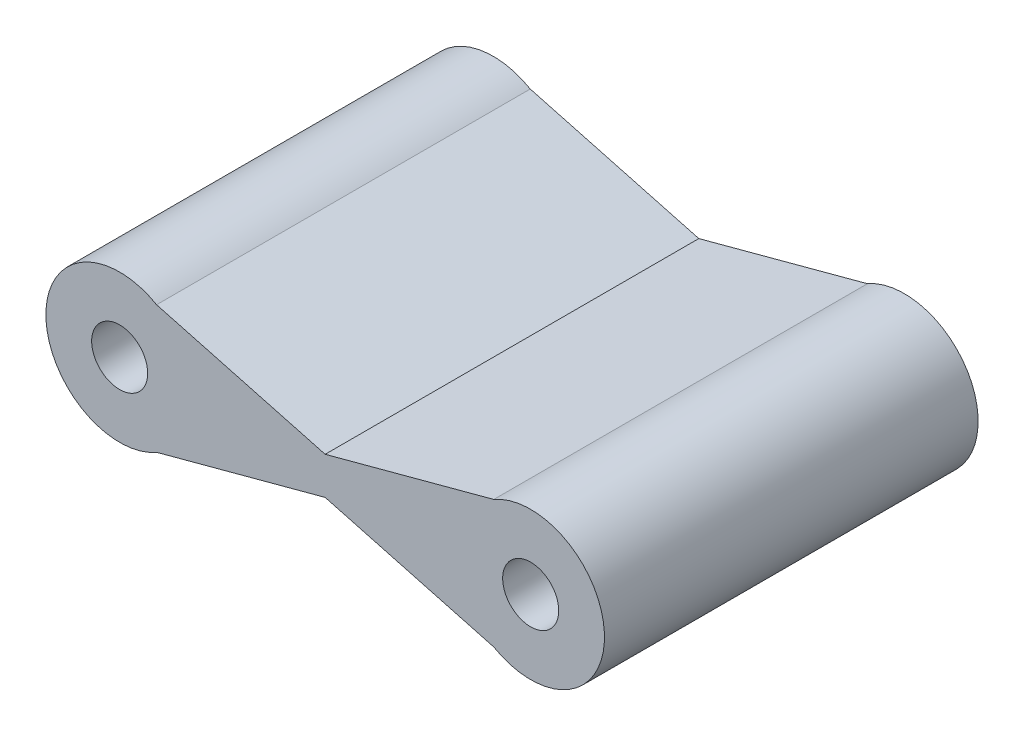
from build123d import *

# Parameters (mm, degrees)
SKETCH1_R           = 0.75
BOSS_EXTRUDE1_DEPTH = 10


with BuildPart() as part:
    # Sketch1 → Boss-Extrude1 (new body)
    with BuildSketch(Plane.XY):
        with BuildLine():
            Line((10.011757676, 2.209971377), (5.5, 1))
            Line((5.5, 1), (0.988242324, 2.209971377))
            ThreePointArc((0.988242324, 2.209971377), (-1.975, 0.5), (0.988242324, -1.209971377))
            Line((0.988242324, -1.209971377), (5.5, 0))
            Line((5.5, 0), (10.011757676, -1.209971377))
            ThreePointArc((10.011757676, -1.209971377), (12.975, 0.5), (10.011757676, 2.209971377))
        make_face()
        with Locations((0, 0.5)):
            Circle(SKETCH1_R, mode=Mode.SUBTRACT)
        with Locations((11, 0.5)):
            Circle(SKETCH1_R, mode=Mode.SUBTRACT)
    extrude(amount=BOSS_EXTRUDE1_DEPTH)


solid = part.part
